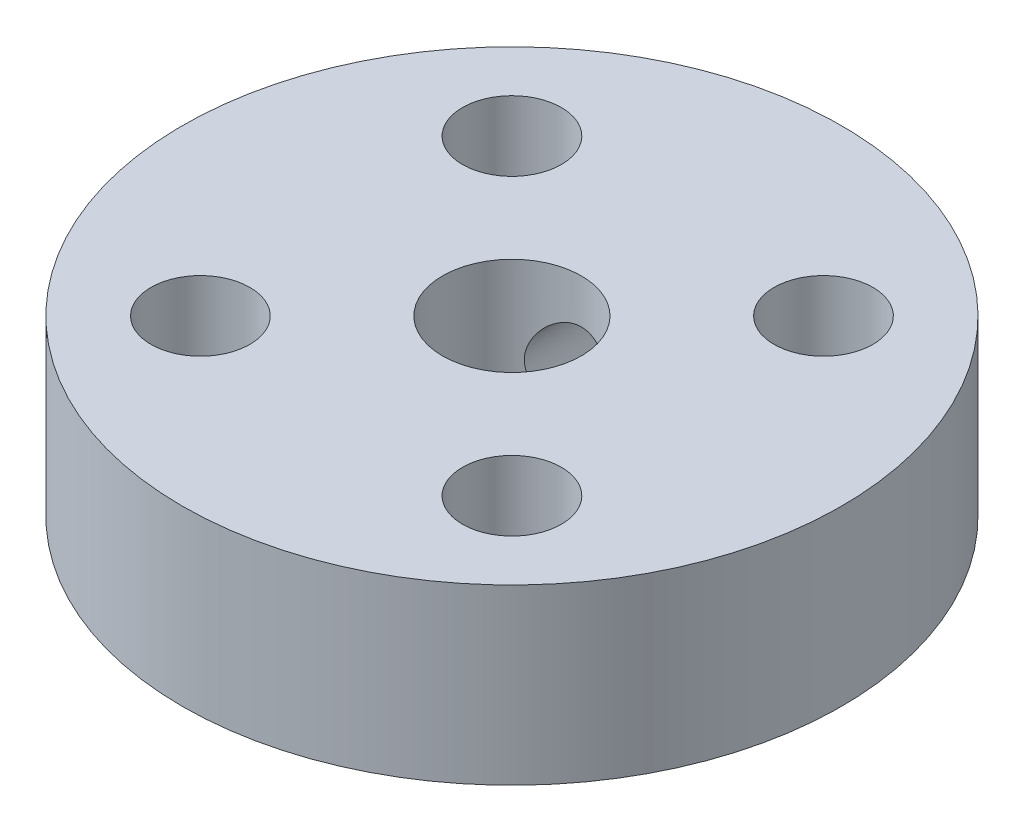
from build123d import *

# Parameters (mm, degrees)
SKETCH1_R           = 9.5
SKETCH1_R_2         = 2
SKETCH1_R_3         = 1.425
BOSS_EXTRUDE1_DEPTH = 5
CUT_EXTRUDE1_REACH  = 21
SKETCH2_R           = 1.225


with BuildPart() as part:
    # Sketch1 → Boss-Extrude1 (new body)
    with BuildSketch(Plane(origin=(0, 0, 0), x_dir=(1, 0, 0), z_dir=(0, 1, 0))):
        Circle(SKETCH1_R)
        Circle(SKETCH1_R_2, mode=Mode.SUBTRACT)
        with Locations((-4.490128061, 4.490128061)):
            Circle(SKETCH1_R_3, mode=Mode.SUBTRACT)
        with Locations((4.490128061, 4.490128061)):
            Circle(SKETCH1_R_3, mode=Mode.SUBTRACT)
        with Locations((4.490128061, -4.490128061)):
            Circle(SKETCH1_R_3, mode=Mode.SUBTRACT)
        with Locations((-4.490128061, -4.490128061)):
            Circle(SKETCH1_R_3, mode=Mode.SUBTRACT)
    extrude(amount=BOSS_EXTRUDE1_DEPTH)

    # Sketch2 → Cut-Extrude1 (cut, up to next)
    with BuildSketch(Plane(origin=(0, 0, -9.5), x_dir=(-1, 0, 0), z_dir=(0, 0, -1)), mode=Mode.PRIVATE) as cut_extrude1_sk1:
        with Locations((0, 2.5)):
            Circle(SKETCH2_R)
    cut_extrude1_tool1 = extrude(cut_extrude1_sk1.sketch, amount=-CUT_EXTRUDE1_REACH, mode=Mode.PRIVATE) & part.part
    add(cut_extrude1_tool1.solids().sort_by_distance((0, 2.5, -9.5))[0], mode=Mode.SUBTRACT)


solid = part.part
